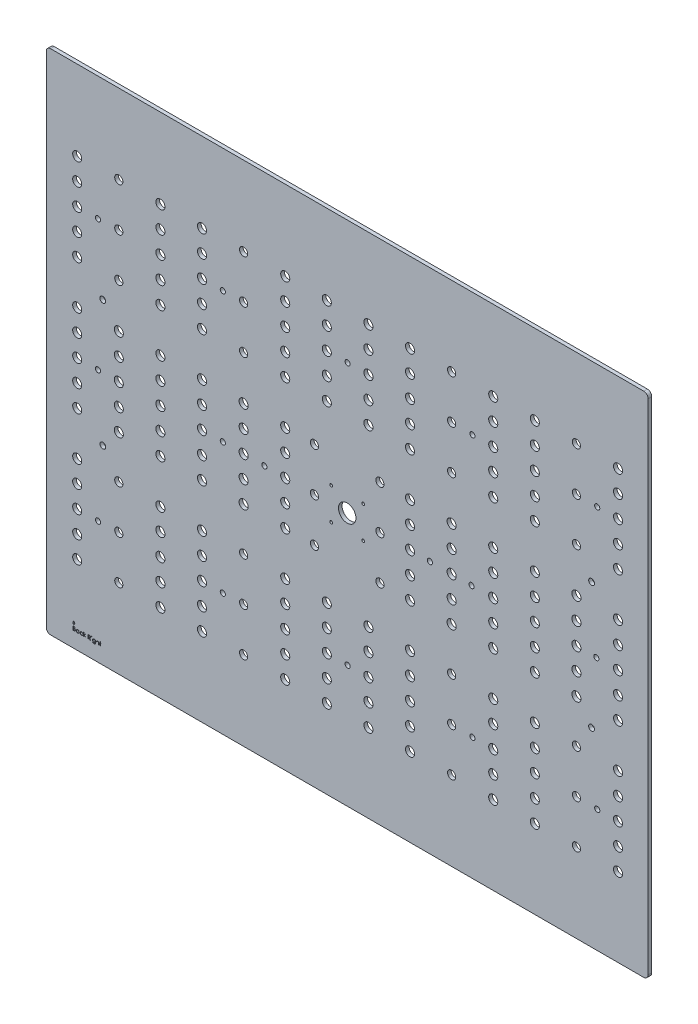
from build123d import *

# Parameters (mm, degrees)
SKETCH1_W                         = 578.0532
SKETCH1_H                         = 495.85372
BOSS_EXTRUDE1_DEPTH               = 3.175
SKETCH8_W                         = 19.431
SKETCH8_H                         = 19.431
CORNERS_DEPTH                     = 4.175
SKETCH13_R                        = 7.62
CAMERA_HOLE_DEPTH                 = 4.175
SKETCH12_R                        = 3.96875
LED_HOLES_DEPTH                   = 4.175
CUT_EXTRUDE7_DEPTH                = 4.175
FILLET1_R                         = 2.54
LPATTERN1_COUNT                   = 14
LPATTERN1_PITCH                   = 36.322
LPATTERN1_COUNT_DIR2              = 3
LPATTERN1_PITCH_DIR2              = 114.3
SKETCH17_R                        = 3.571875
WHITE_LED_DEPTH                   = 4.175
LPATTERN3_COUNT                   = 3
LPATTERN3_PITCH                   = 228.6
LPATTERN3_COUNT_DIR2              = 12
LPATTERN3_PITCH_DIR2              = 36.322
SKETCH18_R                        = 3.571875
WHITE_LED2_DEPTH                  = 4.175
F_8_CLEARANCE_HOLE_LIGHT_STRAP_D  = 4.4958
F_2_CLEARANCE_HOLE_CAMERA_MOUNT_D = 2.4384
LPATTERN7_COUNT                   = 5
LPATTERN7_PITCH                   = 108.966
F_8_CLEARANCE_HOLE_STRAP_HOLES_D  = 4.4958
SKETCH26_W                        = 651.271962381
SKETCH26_H                        = 575.691192957
SKETCH26_W_2                      = 525.4625
SKETCH26_H_2                      = 443.27572
OUTER_CIMENSIONS_TEMP_DEPTH       = 4.175
FILLET2_R                         = 3.81
F_10_CLEARANCE_HOLE1_D            = 5.1054
SKETCH29_W                        = 0.314102564
SKETCH29_H                        = 2.557692307
CUT_EXTRUDE8_DEPTH                = 1.27


with BuildPart() as part:
    # Sketch1 → Boss-Extrude1 (new body)
    with BuildSketch(Plane.XY):
        with Locations((169.253006723, -23.184095462)):
            Rectangle(SKETCH1_W, SKETCH1_H)
    extrude(amount=BOSS_EXTRUDE1_DEPTH)

    # Sketch8 → Corners (cut, through all)
    with BuildSketch(Plane.XY.offset(3.175)):
        with Locations((-110.058093277, 215.027264538)):
            Rectangle(SKETCH8_W, SKETCH8_H)
        with Locations((448.564106723, 215.027264538)):
            Rectangle(SKETCH8_W, SKETCH8_H)
        with Locations((448.564106723, -261.395455462)):
            Rectangle(SKETCH8_W, SKETCH8_H)
        with Locations((-110.058093277, -261.395455462)):
            Rectangle(SKETCH8_W, SKETCH8_H)
    extrude(amount=-CORNERS_DEPTH, mode=Mode.SUBTRACT)

    # Sketch13 → camera hole (cut, through all)
    with BuildSketch(Plane.XY.offset(3.175)):
        with Locations((169.253006723, -23.184095462)):
            Circle(SKETCH13_R)
    extrude(amount=-CAMERA_HOLE_DEPTH, mode=Mode.SUBTRACT)

    # Sketch12 → LED holes (cut, through all)
    with BuildSketch(Plane(origin=(0, 0, 0), x_dir=(-1, 0, 0), z_dir=(0, 0, -1))):
        with Locations((66.458993277, 52.507904538)):
            Circle(SKETCH12_R)
        with Locations((66.458993277, 71.557904538)):
            Circle(SKETCH12_R)
        with Locations((66.458993277, 90.607904538)):
            Circle(SKETCH12_R)
        with Locations((66.458993277, 109.657904538)):
            Circle(SKETCH12_R)
        with Locations((66.458993277, 128.707904538)):
            Circle(SKETCH12_R)
    led_holes = extrude(amount=-LED_HOLES_DEPTH, mode=Mode.SUBTRACT)

    # Sketch15 → Cut-Extrude7 (cut, through all)
    with BuildSketch(Plane.XY.offset(3.175)):
        Polygon((-100.342593277, 224.742764538), (438.848606723, 224.742764538), (438.848606723, 205.311764538), (458.279606723, 205.311764538), (458.279606723, -251.679955462), (438.848606723, -251.679955462), (438.848606723, -271.110955462), (-100.342593277, -271.110955462), (-100.342593277, -251.679955462), (-119.773593277, -251.679955462), (-119.773593277, 205.311764538), (-100.342593277, 205.311764538), align=None)
        Polygon((-99.834593277, 224.234764538), (438.340606723, 224.234764538), (438.340606723, 204.803764538), (457.771606723, 204.803764538), (457.771606723, -251.171955462), (438.340606723, -251.171955462), (438.340606723, -270.602955462), (-99.834593277, -270.602955462), (-99.834593277, -251.171955462), (-119.265593277, -251.171955462), (-119.265593277, 204.803764538), (-99.834593277, 204.803764538), align=None, mode=Mode.SUBTRACT)
    extrude(amount=-CUT_EXTRUDE7_DEPTH, mode=Mode.SUBTRACT)

    # Fillet1
    fillet1_edges = [part.edges().sort_by_distance(p)[0] for p in [
        (-99.834593277, 224.234764538, 1.5875),
        (438.340606723, 224.234764538, 1.5875),
        (457.771606723, 204.803764538, 1.5875),
        (457.771606723, -251.171955462, 1.5875),
        (438.340606723, -270.602955462, 1.5875),
        (-99.834593277, -270.602955462, 1.5875),
        (-119.265593277, -251.171955462, 1.5875),
        (-119.265593277, 204.803764538, 1.5875),
    ]]
    fillet(fillet1_edges, radius=FILLET1_R)

    # LPattern1: LED holes 14 × 3, 10 skipped
    with Locations(*[(i * LPATTERN1_PITCH, -j * LPATTERN1_PITCH_DIR2, 0) for i in range(LPATTERN1_COUNT) for j in range(LPATTERN1_COUNT_DIR2) if (i, j) not in ((0, 0), (1, 0), (1, 2), (4, 0), (4, 2), (6, 1), (7, 1), (9, 0), (9, 2), (12, 0), (12, 2))]):
        add(led_holes, mode=Mode.SUBTRACT)

    # Sketch17 → White LED (cut, through all)
    with BuildSketch(Plane(origin=(0, 0, 0), x_dir=(-1, 0, 0), z_dir=(0, 0, -1))):
        with Locations((30.136993277, 53.015904538)):
            Circle(SKETCH17_R)
        with Locations((30.136993277, 91.115904538)):
            Circle(SKETCH17_R)
        with Locations((30.136993277, 129.215904538)):
            Circle(SKETCH17_R)
    white_led = extrude(amount=-WHITE_LED_DEPTH, mode=Mode.SUBTRACT)

    # LPattern3: White LED 3 × 12, 16 skipped
    with Locations(*[(j * LPATTERN3_PITCH_DIR2, -i * LPATTERN3_PITCH, 0) for i in range(LPATTERN3_COUNT) for j in range(LPATTERN3_COUNT_DIR2) if (i, j) not in ((0, 0), (0, 1), (0, 2), (0, 4), (0, 5), (0, 6), (0, 7), (0, 9), (0, 10), (1, 1), (1, 2), (1, 4), (1, 5), (1, 6), (1, 7), (1, 9), (1, 10))]):
        add(white_led, mode=Mode.SUBTRACT)

    # Sketch18 → White LED2 (cut, through all)
    with BuildSketch(Plane(origin=(0, 0, 0), x_dir=(-1, 0, 0), z_dir=(0, 0, -1))):
        with Locations((-140.678006723, -61.792095462)):
            Circle(SKETCH18_R)
        with Locations((-197.828006723, -61.792095462)):
            Circle(SKETCH18_R)
        with Locations((-197.828006723, -23.692095462)):
            Circle(SKETCH18_R)
        with Locations((-197.828006723, 14.407904538)):
            Circle(SKETCH18_R)
        with Locations((-140.678006723, -23.692095462)):
            Circle(SKETCH18_R)
        with Locations((-140.678006723, 14.407904538)):
            Circle(SKETCH18_R)
    extrude(amount=-WHITE_LED2_DEPTH, mode=Mode.SUBTRACT)

    # #8 Clearance Hole light strap (through all)
    with Locations(Plane(origin=(0, 0, 0), x_dir=(-1, 0, 0), z_dir=(0, 0, -1))):
        with Locations((48.297993277, 90.607904538), (48.297993277, -137.992095462)):
            f_8_clearance_hole_light_strap = Hole(F_8_CLEARANCE_HOLE_LIGHT_STRAP_D / 2)

    # #2 Clearance Hole Camera Mount (through all)
    with Locations(Plane.XY.offset(3.175)):
        with Locations((155.283006723, -9.214095462), (183.223006723, -9.214095462), (183.223006723, -37.154095462), (155.283006723, -37.154095462)):
            Hole(F_2_CLEARANCE_HOLE_CAMERA_MOUNT_D / 2)

    # LPattern7: #8 Clearance Hole light strap ×5
    with Locations(*[(i * LPATTERN7_PITCH, 0, 0) for i in range(1, LPATTERN7_COUNT)]):
        add(f_8_clearance_hole_light_strap, mode=Mode.SUBTRACT)

    # #8 Clearance Hole Strap holes (through all)
    with Locations(Plane.XY.offset(3.175)):
        with Locations((-48.297993277, -23.692095462), (60.668006723, -23.692095462), (96.990006723, -23.692095462), (241.516006723, -23.692095462), (277.838006723, -23.692095462), (386.804006723, -23.692095462)):
            Hole(F_8_CLEARANCE_HOLE_STRAP_HOLES_D / 2)

    # Sketch26 → Outer Cimensions (temp) (cut, through all)
    with BuildSketch(Plane.XY.offset(3.175)):
        with Locations((175.732860109, -14.260001289)):
            Rectangle(SKETCH26_W, SKETCH26_H)
        with Locations((169.253006723, -23.184095462)):
            Rectangle(SKETCH26_W_2, SKETCH26_H_2, mode=Mode.SUBTRACT)
    extrude(amount=-OUTER_CIMENSIONS_TEMP_DEPTH, mode=Mode.SUBTRACT)

    # Fillet2
    fillet2_edges = [part.edges().sort_by_distance(p)[0] for p in [
        (-93.478243277, 198.453764538, 1.5875),
        (431.984256723, 198.453764538, 1.5875),
        (431.984256723, -244.821955462, 1.5875),
        (-93.478243277, -244.821955462, 1.5875),
    ]]
    fillet(fillet2_edges, radius=FILLET2_R)

    # #10 Clearance Hole1 (through all)
    with Locations(Plane.XY.offset(3.175)):
        with Locations((-44.106993277, -78.793166362), (382.613006723, -78.793166362), (382.613006723, 31.408975438), (-44.106993277, 31.408975438)):
            Hole(F_10_CLEARANCE_HOLE1_D / 2)

    # Sketch29 → Cut-Extrude8 (cut)
    with BuildSketch(Plane.XY.offset(3.175)):
        Polygon((-69.411743277, -224.208312288), (-70.427743277, -225.478312288), (-69.919743277, -225.478312288), (-69.919743277, -226.748312288), (-68.903743277, -226.748312288), (-68.903743277, -225.478312288), (-68.395743277, -225.478312288), align=None)
        with BuildLine():
            Line((-69.979025329, -228.033666458), (-69.2961327, -228.033666458))
            add(Edge.make_bspline(
                [(-69.2961327, -228.033666458), (-69.262704222, -228.033842209), (-69.197911512, -228.034182857), (-69.10369207, -228.039465988), (-69.015443259, -228.046669658), (-68.933139487, -228.058099751), (-68.856818785, -228.071891528), (-68.786251147, -228.088593344), (-68.721660975, -228.108619957), (-68.644548239, -228.140466239), (-68.556627578, -228.187789407), (-68.461429185, -228.257717972), (-68.380024946, -228.343250435), (-68.309838629, -228.439733091), (-68.254037509, -228.545868862), (-68.213668212, -228.659128051), (-68.188110336, -228.778049793), (-68.185481902, -228.859692971), (-68.184153534, -228.900954119)],
                knots=[0, 0, 0, 0, 0.00010027, 0.000194349, 0.000283026, 0.000365821, 0.000443519, 0.000515622, 0.000583254, 0.00064614, 0.000765662, 0.000881909, 0.000998927, 0.001118415, 0.001238844, 0.00135727, 0.001478274, 0.001601912, 0.001601912, 0.001601912, 0.001601912], degree=3))
            add(Edge.make_bspline(
                [(-68.184153534, -228.900954119), (-68.185246752, -228.939606674), (-68.187395029, -229.015562591), (-68.207937789, -229.126656701), (-68.240098457, -229.23240792), (-68.284803706, -229.332430305), (-68.342905703, -229.424463918), (-68.411764021, -229.509251184), (-68.494840824, -229.583202241), (-68.557084064, -229.624545144), (-68.588700809, -229.645545465)],
                knots=[0, 0, 0, 0, 0.000115857, 0.00022767, 0.000337672, 0.000446877, 0.000555233, 0.000663318, 0.000773539, 0.000887324, 0.000887324, 0.000887324, 0.000887324], degree=3))
            add(Edge.make_bspline(
                [(-68.588700809, -229.645545465), (-68.548940382, -229.660810464), (-68.472868834, -229.690016188), (-68.368182822, -229.741651652), (-68.277987977, -229.797813763), (-68.201590831, -229.859145613), (-68.136253176, -229.925254424), (-68.079200234, -229.997109538), (-68.03051886, -230.075648296), (-67.988805937, -230.160051831), (-67.956257181, -230.249458299), (-67.931881276, -230.343029075), (-67.917913827, -230.440428631), (-67.915926186, -230.50671401), (-67.914922764, -230.540176875)],
                knots=[0, 0, 0, 0, 0.000127722, 0.000244363, 0.000349599, 0.000445847, 0.000537565, 0.000627901, 0.000720503, 0.000814257, 0.000909859, 0.001005428, 0.001103887, 0.001204268, 0.001204268, 0.001204268, 0.001204268], degree=3))
            add(Edge.make_bspline(
                [(-67.914922764, -230.540176875), (-67.915899611, -230.574343747), (-67.917821582, -230.641568025), (-67.932001554, -230.74032316), (-67.956010661, -230.834698107), (-67.989081808, -230.925303289), (-68.032244122, -231.011963424), (-68.084772087, -231.094776688), (-68.14740365, -231.172911018), (-68.217466519, -231.247234641), (-68.296728665, -231.314062429), (-68.382244419, -231.373578135), (-68.475090739, -231.422524198), (-68.573742733, -231.463640219), (-68.67930705, -231.495047418), (-68.791309657, -231.517019991), (-68.909653959, -231.531825028), (-68.99086371, -231.533042233), (-69.032510906, -231.533666458)],
                knots=[0, 0, 0, 0, 0.000102481, 0.000201635, 0.000298562, 0.000394165, 0.000490425, 0.000588455, 0.000687769, 0.000790423, 0.000894381, 0.000998232, 0.001102369, 0.001208616, 0.001318415, 0.001432129, 0.001550749, 0.00167562, 0.00167562, 0.00167562, 0.00167562], degree=3))
            Line((-69.032510906, -231.533666458), (-69.979025329, -231.533666458))
            Line((-69.979025329, -231.533666458), (-69.979025329, -228.033666458))
        make_face()
        with BuildLine():
            Line((-69.664922764, -228.392640817), (-69.664922764, -229.514435689))
            Line((-69.664922764, -229.514435689), (-69.453885104, -229.514435689))
            add(Edge.make_bspline(
                [(-69.453885104, -229.514435689), (-69.423036309, -229.514035766), (-69.36343015, -229.513263033), (-69.277110253, -229.511049516), (-69.196985235, -229.504851473), (-69.123193402, -229.498655211), (-69.055850958, -229.488580623), (-68.995107096, -229.4765885), (-68.940008499, -229.463905595), (-68.876468954, -229.442336108), (-68.804396005, -229.410458433), (-68.727562901, -229.360986597), (-68.659828432, -229.302062244), (-68.602631244, -229.234071282), (-68.555819773, -229.159205096), (-68.523306058, -229.078658216), (-68.501258774, -228.994438084), (-68.499267243, -228.936619831), (-68.498256098, -228.907264215)],
                knots=[0, 0, 0, 0, 9.2559e-05, 0.000178842, 0.000258967, 0.000333616, 0.000400942, 0.000463093, 0.000519379, 0.000570374, 0.000664201, 0.000755025, 0.000843472, 0.000932526, 0.001020669, 0.001107124, 0.001192318, 0.001280185, 0.001280185, 0.001280185, 0.001280185], degree=3))
            add(Edge.make_bspline(
                [(-68.498256098, -228.907264215), (-68.498782278, -228.887838443), (-68.499814438, -228.849732671), (-68.508267741, -228.794183317), (-68.522635315, -228.741939565), (-68.541089608, -228.692285454), (-68.566878297, -228.646773604), (-68.59724176, -228.603830408), (-68.63392745, -228.56491829), (-68.675684763, -228.528548792), (-68.723693386, -228.496304264), (-68.777924678, -228.468063501), (-68.839112355, -228.445322724), (-68.90622521, -228.425406571), (-68.980296297, -228.411418278), (-69.060470851, -228.39976489), (-69.14740557, -228.393832148), (-69.207550672, -228.393046785), (-69.238640713, -228.392640817)],
                knots=[0, 0, 0, 0, 5.8261e-05, 0.000114285, 0.000168029, 0.000220632, 0.000272728, 0.000324483, 0.000378062, 0.000432741, 0.000490301, 0.000551137, 0.000615721, 0.000685833, 0.000760908, 0.00084162, 0.000928788, 0.00102206, 0.00102206, 0.00102206, 0.00102206], degree=3))
            Line((-69.238640713, -228.392640817), (-69.664922764, -228.392640817))
        make_face(mode=Mode.SUBTRACT)
        with BuildLine():
            Line((-69.664922764, -229.873410048), (-69.664922764, -231.174692099))
            Line((-69.664922764, -231.174692099), (-69.217607059, -231.174692099))
            add(Edge.make_bspline(
                [(-69.217607059, -231.174692099), (-69.185588133, -231.174308352), (-69.123875875, -231.17356873), (-69.034774645, -231.171154175), (-68.952191541, -231.165661899), (-68.876503405, -231.15701605), (-68.806892953, -231.1476376), (-68.74419525, -231.13502632), (-68.687902056, -231.120577359), (-68.622627748, -231.098243187), (-68.54912424, -231.063546716), (-68.469913384, -231.011232489), (-68.399487166, -230.948909182), (-68.339681906, -230.876778268), (-68.290668918, -230.798346941), (-68.255013463, -230.715201591), (-68.233022606, -230.628716063), (-68.230360437, -230.569749351), (-68.229025329, -230.540176875)],
                knots=[0, 0, 0, 0, 9.6064e-05, 0.000185151, 0.000267373, 0.000344257, 0.000413665, 0.000478015, 0.000536005, 0.000587888, 0.000684801, 0.000778918, 0.000871787, 0.000965866, 0.001059062, 0.00114827, 0.001236355, 0.001324974, 0.001324974, 0.001324974, 0.001324974], degree=3))
            add(Edge.make_bspline(
                [(-68.229025329, -230.540176875), (-68.229301433, -230.521683535), (-68.229849188, -230.484995153), (-68.238109803, -230.431079334), (-68.250123673, -230.37885346), (-68.265655107, -230.32817572), (-68.288274574, -230.279962344), (-68.314681119, -230.233259784), (-68.34564252, -230.188006305), (-68.393886686, -230.130794051), (-68.464058671, -230.064877038), (-68.563765446, -230.000339536), (-68.677137744, -229.948291729), (-68.759365237, -229.926192252), (-68.801841835, -229.914776234)],
                knots=[0, 0, 0, 0, 5.5429e-05, 0.000109963, 0.000163198, 0.000216191, 0.000268588, 0.000322593, 0.000377046, 0.000432793, 0.000546889, 0.000664343, 0.000787646, 0.000919405, 0.000919405, 0.000919405, 0.000919405], degree=3))
            add(Edge.make_bspline(
                [(-68.801841835, -229.914776234), (-68.818870931, -229.91132115), (-68.855793523, -229.903829815), (-68.916001104, -229.895922112), (-68.984736973, -229.888877052), (-69.06215985, -229.883665895), (-69.148367691, -229.878279351), (-69.24354461, -229.87618453), (-69.347301924, -229.87368527), (-69.419294297, -229.873504136), (-69.456689591, -229.873410048)],
                knots=[0, 0, 0, 0, 5.2115e-05, 0.000112995, 0.000182062, 0.000259389, 0.000345767, 0.00044116, 0.000544948, 0.000657129, 0.000657129, 0.000657129, 0.000657129], degree=3))
            Line((-69.456689591, -229.873410048), (-69.664922764, -229.873410048))
        make_face(mode=Mode.SUBTRACT)
        with BuildLine():
            Line((-64.684153534, -228.975974151), (-64.684153534, -231.533666458))
            Line((-64.684153534, -231.533666458), (-64.998256098, -231.533666458))
            Line((-64.998256098, -231.533666458), (-64.998256098, -231.091258606))
            add(Edge.make_bspline(
                [(-64.998256098, -231.091258606), (-65.033674888, -231.1312982), (-65.102795104, -231.209435971), (-65.218236222, -231.311518143), (-65.3406044, -231.395896465), (-65.469305721, -231.464046381), (-65.604223964, -231.515238437), (-65.745060051, -231.551624596), (-65.891871432, -231.575018431), (-65.992123787, -231.577354453), (-66.042927572, -231.578538253)],
                knots=[0, 0, 0, 0, 0.000160263, 0.000312755, 0.000460949, 0.000605216, 0.000748578, 0.000892786, 0.001041028, 0.001193333, 0.001193333, 0.001193333, 0.001193333], degree=3))
            add(Edge.make_bspline(
                [(-66.042927572, -231.578538253), (-66.088095526, -231.577311881), (-66.177168731, -231.574893421), (-66.308197808, -231.556131117), (-66.434290057, -231.526000495), (-66.55556463, -231.484099606), (-66.671236776, -231.428518784), (-66.782296872, -231.361977536), (-66.888169564, -231.282736706), (-66.987241103, -231.192148678), (-67.078473104, -231.093753691), (-67.158534376, -230.988808144), (-67.225287456, -230.87776584), (-67.281107537, -230.762032686), (-67.324103881, -230.640717766), (-67.354077516, -230.514240598), (-67.372817962, -230.382750725), (-67.375235423, -230.293211202), (-67.376461226, -230.247809087)],
                knots=[0, 0, 0, 0, 0.000135464, 0.00026714, 0.000396211, 0.000523931, 0.000651257, 0.000780517, 0.000911767, 0.001047265, 0.00118272, 0.001313831, 0.001442491, 0.001570752, 0.001698704, 0.001827775, 0.001960146, 0.00209631, 0.00209631, 0.00209631, 0.00209631], degree=3))
            add(Edge.make_bspline(
                [(-67.376461226, -230.247809087), (-67.375208255, -230.203345383), (-67.372731198, -230.11544304), (-67.354277978, -229.986164342), (-67.323246969, -229.861646081), (-67.279699122, -229.742289138), (-67.223857167, -229.627949088), (-67.15592908, -229.518545063), (-67.075909955, -229.413775665), (-66.983657548, -229.316104438), (-66.883722778, -229.225883824), (-66.776814047, -229.147474779), (-66.665590766, -229.07975793), (-66.548327755, -229.026104454), (-66.42676065, -228.982695349), (-66.299807204, -228.952662381), (-66.167995626, -228.93496506), (-66.078505134, -228.932402296), (-66.033111867, -228.931102356)],
                knots=[0, 0, 0, 0, 0.000133363, 0.00026365, 0.000390846, 0.000517716, 0.000644083, 0.000771912, 0.000903449, 0.001038867, 0.001174416, 0.001306792, 0.001436052, 0.00156435, 0.001692963, 0.001822716, 0.001954992, 0.002091156, 0.002091156, 0.002091156, 0.002091156], degree=3))
            add(Edge.make_bspline(
                [(-66.033111867, -228.931102356), (-65.980912008, -228.932540107), (-65.878550548, -228.93535947), (-65.728822539, -228.958822198), (-65.587178061, -228.998460665), (-65.452523709, -229.052378163), (-65.325343023, -229.124026892), (-65.206840038, -229.214406853), (-65.095774555, -229.32294804), (-65.031394263, -229.406318484), (-64.998256098, -229.449231362)],
                knots=[0, 0, 0, 0, 0.00015654, 0.000306968, 0.000453261, 0.000596998, 0.000741098, 0.000889738, 0.001042937, 0.001205434, 0.001205434, 0.001205434, 0.001205434], degree=3))
            Line((-64.998256098, -229.449231362), (-64.998256098, -228.975974151))
            Line((-64.998256098, -228.975974151), (-64.684153534, -228.975974151))
        make_face()
        with BuildLine():
            add(Edge.make_bspline(
                [(-66.028905136, -229.24520492), (-66.074819474, -229.246838558), (-66.165447074, -229.250063099), (-66.298491076, -229.275236594), (-66.42580449, -229.317121188), (-66.546750565, -229.374403089), (-66.659418781, -229.446431826), (-66.760112452, -229.533553209), (-66.849655153, -229.633390224), (-66.924963418, -229.745492334), (-66.986353915, -229.865670425), (-67.029520946, -229.991294863), (-67.057990194, -230.120099841), (-67.060898714, -230.207462526), (-67.062358662, -230.251314696)],
                knots=[0, 0, 0, 0, 0.000137677, 0.000271753, 0.000404561, 0.000538791, 0.000672205, 0.000804452, 0.00093703, 0.001073348, 0.00120849, 0.001340643, 0.001470999, 0.001602378, 0.001602378, 0.001602378, 0.001602378], degree=3))
            add(Edge.make_bspline(
                [(-67.062358662, -230.251314696), (-67.060493769, -230.294904803), (-67.056771292, -230.381914159), (-67.030020597, -230.510894735), (-66.985140724, -230.636548778), (-66.923898661, -230.757809771), (-66.847212036, -230.870393871), (-66.758323384, -230.972133994), (-66.656373103, -231.059623582), (-66.543445596, -231.132861156), (-66.422837625, -231.192023677), (-66.296003694, -231.233189316), (-66.165328055, -231.259767097), (-66.076475722, -231.262871574), (-66.031709623, -231.264435689)],
                knots=[0, 0, 0, 0, 0.000130727, 0.000260941, 0.000393327, 0.000530037, 0.000667328, 0.000800955, 0.000934191, 0.001068956, 0.001203792, 0.001335934, 0.001468075, 0.001602253, 0.001602253, 0.001602253, 0.001602253], degree=3))
            add(Edge.make_bspline(
                [(-66.031709623, -231.264435689), (-65.986263121, -231.262775725), (-65.895874534, -231.259474222), (-65.762435826, -231.234192956), (-65.632940864, -231.192424158), (-65.509153635, -231.134525031), (-65.393837504, -231.062767675), (-65.290339626, -230.978760584), (-65.202823658, -230.8810574), (-65.128631048, -230.773680947), (-65.070455632, -230.655968951), (-65.028079573, -230.53063476), (-65.003025667, -230.397674012), (-64.999867937, -230.306810085), (-64.998256098, -230.260429279)],
                knots=[0, 0, 0, 0, 0.000136278, 0.000271043, 0.000405851, 0.000543552, 0.000679927, 0.000812429, 0.000941985, 0.001072088, 0.00120284, 0.001334538, 0.001467925, 0.001607002, 0.001607002, 0.001607002, 0.001607002], degree=3))
            add(Edge.make_bspline(
                [(-64.998256098, -230.260429279), (-64.999215754, -230.225091448), (-65.001104662, -230.155535415), (-65.015535231, -230.053407898), (-65.038490158, -229.955674172), (-65.070836328, -229.862231482), (-65.113327612, -229.773596467), (-65.164575378, -229.689132707), (-65.225480828, -229.609279495), (-65.295063524, -229.535136424), (-65.371228726, -229.467509962), (-65.451823267, -229.407145722), (-65.537802014, -229.357556949), (-65.627719051, -229.316515677), (-65.721730385, -229.283856527), (-65.820601005, -229.262068834), (-65.923279992, -229.247108513), (-65.993326047, -229.245846132), (-66.028905136, -229.24520492)],
                knots=[0, 0, 0, 0, 0.000105983, 0.000208608, 0.000308773, 0.00040678, 0.000504626, 0.000603105, 0.000702667, 0.00080535, 0.000907651, 0.001007914, 0.001106881, 0.00120477, 0.001304102, 0.001404791, 0.00150811, 0.001614764, 0.001614764, 0.001614764, 0.001614764], degree=3))
        make_face(mode=Mode.SUBTRACT)
        with BuildLine():
            Line((-61.453384303, -229.530561491), (-61.716304976, -229.693922869))
            add(Edge.make_bspline(
                [(-61.716304976, -229.693922869), (-61.745134841, -229.658094475), (-61.801881537, -229.587572365), (-61.900420773, -229.496562431), (-62.005432187, -229.41839539), (-62.118710235, -229.354691639), (-62.240096035, -229.305470188), (-62.369110886, -229.270639983), (-62.505736391, -229.24893574), (-62.59940159, -229.246468903), (-62.64739472, -229.24520492)],
                knots=[0, 0, 0, 0, 0.0001378, 0.000271237, 0.000401088, 0.000529797, 0.000659994, 0.000793002, 0.000929944, 0.001073845, 0.001073845, 0.001073845, 0.001073845], degree=3))
            add(Edge.make_bspline(
                [(-62.64739472, -229.24520492), (-62.685753677, -229.246261762), (-62.761300599, -229.248343184), (-62.872206753, -229.261353678), (-62.977849106, -229.284995686), (-63.078889815, -229.316146643), (-63.174610233, -229.357896933), (-63.265261152, -229.408706689), (-63.351646642, -229.467756729), (-63.431263383, -229.536167274), (-63.50409239, -229.610565942), (-63.567191304, -229.690319637), (-63.622128237, -229.773039529), (-63.665234194, -229.860791271), (-63.700509364, -229.951567324), (-63.723716084, -230.04708118), (-63.73918078, -230.146109187), (-63.740950108, -230.213627527), (-63.741845841, -230.247809087)],
                knots=[0, 0, 0, 0, 0.000115089, 0.000226664, 0.000334347, 0.000439455, 0.000543394, 0.000646972, 0.000750824, 0.000856758, 0.000961376, 0.00106266, 0.001161449, 0.00125865, 0.001355399, 0.001453007, 0.001552955, 0.001655437, 0.001655437, 0.001655437, 0.001655437], degree=3))
            add(Edge.make_bspline(
                [(-63.741845841, -230.247809087), (-63.740066589, -230.292578298), (-63.736532059, -230.381513493), (-63.708830599, -230.512791595), (-63.663486192, -230.639715286), (-63.601428341, -230.761383423), (-63.522951207, -230.873977578), (-63.430778643, -230.974961032), (-63.32485956, -231.062377061), (-63.206127229, -231.134849586), (-63.077369486, -231.193110953), (-62.939979381, -231.234618286), (-62.795079601, -231.259670659), (-62.695872854, -231.262826602), (-62.645291354, -231.264435689)],
                knots=[0, 0, 0, 0, 0.000134224, 0.00026664, 0.000400581, 0.000537609, 0.000675117, 0.000811087, 0.000946551, 0.001085679, 0.001227203, 0.001369372, 0.001515181, 0.001666857, 0.001666857, 0.001666857, 0.001666857], degree=3))
            add(Edge.make_bspline(
                [(-62.645291354, -231.264435689), (-62.59893617, -231.263136192), (-62.507835931, -231.260582335), (-62.374668646, -231.239053372), (-62.247888736, -231.203809738), (-62.127500705, -231.154662088), (-62.013724539, -231.091134572), (-61.907295364, -231.012775402), (-61.806095426, -230.921838801), (-61.746598449, -230.85152083), (-61.716304976, -230.815717741)],
                knots=[0, 0, 0, 0, 0.000138999, 0.00027317, 0.000403475, 0.000533023, 0.000662344, 0.000793326, 0.000928824, 0.001069379, 0.001069379, 0.001069379, 0.001069379], degree=3))
            Line((-61.716304976, -230.815717741), (-61.453384303, -230.988193702))
            add(Edge.make_bspline(
                [(-61.453384303, -230.988193702), (-61.468972005, -231.011084429), (-61.500095672, -231.056789906), (-61.552123298, -231.121234022), (-61.608243129, -231.181555705), (-61.668236226, -231.237674095), (-61.731319236, -231.290932114), (-61.799647146, -231.338783688), (-61.871016757, -231.383918511), (-61.946265915, -231.424531383), (-62.024616613, -231.461037705), (-62.105958602, -231.492428876), (-62.189938415, -231.519398982), (-62.276654791, -231.540836328), (-62.36627869, -231.557947167), (-62.458578324, -231.569300868), (-62.553521906, -231.577776149), (-62.617694057, -231.578282016), (-62.650199207, -231.578538253)],
                knots=[0, 0, 0, 0, 8.3056e-05, 0.000165835, 0.000248187, 0.000330026, 0.000412165, 0.000495625, 0.000580051, 0.000665384, 0.00075196, 0.000839196, 0.00092678, 0.001016395, 0.001107013, 0.001200326, 0.001295291, 0.001392769, 0.001392769, 0.001392769, 0.001392769], degree=3))
            add(Edge.make_bspline(
                [(-62.650199207, -231.578538253), (-62.69981009, -231.577646974), (-62.797047783, -231.575900059), (-62.93937029, -231.556691583), (-63.075383957, -231.527733967), (-63.205042315, -231.486170233), (-63.32836555, -231.432665458), (-63.445238668, -231.367308543), (-63.555274686, -231.289556753), (-63.657385469, -231.200793984), (-63.751166915, -231.104553343), (-63.831693105, -231.000703425), (-63.901538376, -230.893062377), (-63.957625919, -230.779252851), (-64.002272845, -230.660787479), (-64.032777678, -230.536717239), (-64.052507416, -230.408064985), (-64.054790795, -230.320332103), (-64.055948406, -230.275853958)],
                knots=[0, 0, 0, 0, 0.000148744, 0.000291539, 0.000430022, 0.000565498, 0.000699266, 0.000832672, 0.000966504, 0.001102706, 0.001238073, 0.00136893, 0.00149632, 0.001622368, 0.001748823, 0.001875338, 0.002005032, 0.002138395, 0.002138395, 0.002138395, 0.002138395], degree=3))
            add(Edge.make_bspline(
                [(-64.055948406, -230.275853958), (-64.055507389, -230.245675524), (-64.054630135, -230.185645637), (-64.044568208, -230.09655057), (-64.031569735, -230.008642025), (-64.009543998, -229.923034305), (-63.984103366, -229.838429015), (-63.951627834, -229.755845914), (-63.913532439, -229.674901241), (-63.870280492, -229.595803511), (-63.821591747, -229.519853972), (-63.767710514, -229.448100307), (-63.710666177, -229.379680542), (-63.647790065, -229.316956781), (-63.581750412, -229.25742059), (-63.510678836, -229.202662465), (-63.434982984, -229.152521475), (-63.355799662, -229.106070459), (-63.27317495, -229.064711024), (-63.18760828, -229.029077786), (-63.099615251, -228.99862521), (-63.009055107, -228.974516291), (-62.916528933, -228.954298868), (-62.821307595, -228.941581021), (-62.723755373, -228.932594748), (-62.657699351, -228.931603956), (-62.6242577, -228.931102356)],
                knots=[0, 0, 0, 0, 9.0488e-05, 0.000179996, 0.000268751, 0.000356836, 0.000444879, 0.000533675, 0.000622751, 0.00071312, 0.000803944, 0.000893127, 0.000982181, 0.001070925, 0.00115931, 0.001248782, 0.001339788, 0.001431538, 0.001524036, 0.001616746, 0.001709427, 0.001803141, 0.001897749, 0.001993333, 0.002091151, 0.002191451, 0.002191451, 0.002191451, 0.002191451], degree=3))
            add(Edge.make_bspline(
                [(-62.6242577, -228.931102356), (-62.582377592, -228.932024247), (-62.498826713, -228.933863421), (-62.374886006, -228.949342073), (-62.252770812, -228.97267849), (-62.134623709, -229.007251319), (-62.021877194, -229.049114975), (-61.916341744, -229.09612769), (-61.82050164, -229.150722293), (-61.732574051, -229.210442407), (-61.652394534, -229.277803313), (-61.579140041, -229.35361027), (-61.511308392, -229.43746875), (-61.47285168, -229.499274481), (-61.453384303, -229.530561491)],
                knots=[0, 0, 0, 0, 0.000125597, 0.000250566, 0.00037418, 0.000498223, 0.000619345, 0.000734815, 0.00084439, 0.000949794, 0.001053299, 0.001157917, 0.001265662, 0.001376119, 0.001376119, 0.001376119, 0.001376119], degree=3))
        make_face()
        Polygon((-60.825179175, -227.943922869), (-60.511076611, -227.943922869), (-60.511076611, -230.019243382), (-59.347214431, -228.975974151), (-58.895691995, -228.975974151), (-60.246052572, -230.187512612), (-58.761076611, -231.533666458), (-59.211897925, -231.533666458), (-60.511076611, -230.355080721), (-60.511076611, -231.533666458), (-60.825179175, -231.533666458), align=None)
        with BuildLine():
            Line((-56.966204816, -228.033666458), (-56.265784143, -228.033666458))
            add(Edge.make_bspline(
                [(-56.265784143, -228.033666458), (-56.219043014, -228.033822044), (-56.12929487, -228.034120787), (-56.000721599, -228.03578655), (-55.883894502, -228.040560905), (-55.778874663, -228.044669489), (-55.685664008, -228.05216143), (-55.603976717, -228.059322077), (-55.53418902, -228.068695738), (-55.491943169, -228.077401161), (-55.472815393, -228.081342741)],
                knots=[0, 0, 0, 0, 0.000140226, 0.00026925, 0.000385712, 0.000490995, 0.000584507, 0.000666202, 0.000736998, 0.000795574, 0.000795574, 0.000795574, 0.000795574], degree=3))
            add(Edge.make_bspline(
                [(-55.472815393, -228.081342741), (-55.447208769, -228.087669506), (-55.396541779, -228.10018807), (-55.323591713, -228.12664767), (-55.254077389, -228.157267295), (-55.188287565, -228.193231015), (-55.126551774, -228.234805795), (-55.068233463, -228.281273917), (-55.013067999, -228.332381123), (-54.963286369, -228.389415965), (-54.916347318, -228.449252474), (-54.876758691, -228.513956231), (-54.842632211, -228.581617759), (-54.815461694, -228.652925176), (-54.793583721, -228.727186948), (-54.778157481, -228.805075745), (-54.768906294, -228.88623672), (-54.767964438, -228.941594629), (-54.767486867, -228.969664055)],
                knots=[0, 0, 0, 0, 7.9081e-05, 0.000156475, 0.000232432, 0.000306798, 0.00038108, 0.000455429, 0.000530331, 0.000606314, 0.000682321, 0.000758201, 0.000833453, 0.000909362, 0.000986794, 0.001065445, 0.001147284, 0.001231465, 0.001231465, 0.001231465, 0.001231465], degree=3))
            add(Edge.make_bspline(
                [(-54.767486867, -228.969664055), (-54.768955865, -229.016299159), (-54.771822261, -229.107296327), (-54.798547365, -229.239357209), (-54.842323884, -229.362546523), (-54.902647173, -229.476709161), (-54.979466649, -229.579619806), (-55.07179144, -229.670010262), (-55.179673052, -229.745650174), (-55.280102368, -229.798102979), (-55.368816567, -229.831695888), (-55.44184988, -229.855332247), (-55.521516858, -229.873594212), (-55.607054192, -229.889954344), (-55.698817848, -229.902306038), (-55.796587887, -229.911352632), (-55.900434039, -229.917006681), (-55.971773108, -229.917848686), (-56.008472444, -229.918281843)],
                knots=[0, 0, 0, 0, 0.000139777, 0.000272741, 0.000402249, 0.000530843, 0.000658588, 0.000786009, 0.000916741, 0.001052522, 0.001124656, 0.001201155, 0.001282612, 0.001369656, 0.001462366, 0.001560247, 0.001664165, 0.001774261, 0.001774261, 0.001774261, 0.001774261], degree=3))
            Line((-56.008472444, -229.918281843), (-54.722615072, -231.533666458))
            Line((-54.722615072, -231.533666458), (-55.111036547, -231.533666458))
            Line((-55.111036547, -231.533666458), (-56.396893918, -229.918281843))
            Line((-56.396893918, -229.918281843), (-56.652102252, -229.918281843))
            Line((-56.652102252, -229.918281843), (-56.652102252, -231.533666458))
            Line((-56.652102252, -231.533666458), (-56.966204816, -231.533666458))
            Line((-56.966204816, -231.533666458), (-56.966204816, -228.033666458))
        make_face()
        with BuildLine():
            Line((-56.652102252, -228.392640817), (-56.652102252, -229.559307484))
            Line((-56.652102252, -229.559307484), (-56.011276931, -229.564215337))
            add(Edge.make_bspline(
                [(-56.011276931, -229.564215337), (-55.981356892, -229.564228573), (-55.923363335, -229.56425423), (-55.83946267, -229.560260453), (-55.761342559, -229.555717135), (-55.689301806, -229.54876779), (-55.623308231, -229.539811718), (-55.563394818, -229.528608734), (-55.509463766, -229.515556671), (-55.446565228, -229.495355045), (-55.376328696, -229.463349027), (-55.299997236, -229.416783528), (-55.234994899, -229.358214409), (-55.180077036, -229.291240953), (-55.135947605, -229.217604704), (-55.10483555, -229.138188335), (-55.085093108, -229.054996737), (-55.082764563, -228.997818629), (-55.081589431, -228.968962933)],
                knots=[0, 0, 0, 0, 8.9746e-05, 0.000173954, 0.000251933, 0.000324488, 0.000391021, 0.000451663, 0.000507268, 0.000557378, 0.000649639, 0.000738152, 0.000824558, 0.000910739, 0.000997194, 0.001080909, 0.00116578, 0.001252248, 0.001252248, 0.001252248, 0.001252248], degree=3))
            add(Edge.make_bspline(
                [(-55.081589431, -228.968962933), (-55.082791552, -228.940816359), (-55.085173718, -228.88504012), (-55.104622486, -228.80338421), (-55.137511867, -228.72631726), (-55.181834105, -228.654152775), (-55.23583326, -228.588647039), (-55.299151073, -228.532599886), (-55.370056268, -228.486350421), (-55.436327467, -228.456796041), (-55.495561679, -228.438676188), (-55.546991339, -228.425925024), (-55.605102817, -228.415680555), (-55.670178275, -228.407472494), (-55.741939906, -228.40041755), (-55.820750557, -228.395665771), (-55.906087338, -228.392851907), (-55.965234269, -228.392712818), (-55.995852252, -228.392640817)],
                knots=[0, 0, 0, 0, 8.4371e-05, 0.000167192, 0.000250141, 0.000334794, 0.000420435, 0.000503871, 0.000587493, 0.000673488, 0.0007205, 0.000773215, 0.000832351, 0.0008974, 0.000969955, 0.001048634, 0.001134217, 0.001226067, 0.001226067, 0.001226067, 0.001226067], degree=3))
            Line((-55.995852252, -228.392640817), (-56.652102252, -228.392640817))
        make_face(mode=Mode.SUBTRACT)
        with BuildLine():
            add(Edge.make_bspline(
                [(-53.9836327, -227.899051074), (-53.964141385, -227.899955226), (-53.925973645, -227.90172573), (-53.870780377, -227.916887207), (-53.820523365, -227.942586893), (-53.775945632, -227.977066574), (-53.737693745, -228.017616017), (-53.710913035, -228.064876985), (-53.693700639, -228.115935624), (-53.691622084, -228.151550713), (-53.69056379, -228.169684087)],
                knots=[0, 0, 0, 0, 5.84e-05, 0.000114358, 0.000170171, 0.000226684, 0.000282761, 0.000336156, 0.000388483, 0.00044276, 0.00044276, 0.00044276, 0.00044276], degree=3))
            add(Edge.make_bspline(
                [(-53.69056379, -228.169684087), (-53.69164595, -228.18734674), (-53.693785252, -228.222263715), (-53.71089974, -228.272437187), (-53.737921978, -228.31904147), (-53.775921104, -228.359512181), (-53.820529865, -228.393972801), (-53.87077865, -228.419677539), (-53.925974099, -228.434837677), (-53.964141538, -228.436608366), (-53.9836327, -228.437512612)],
                knots=[0, 0, 0, 0, 5.2882e-05, 0.000104542, 0.000157332, 0.000213408, 0.000269922, 0.000325735, 0.000381693, 0.000440092, 0.000440092, 0.000440092, 0.000440092], degree=3))
            add(Edge.make_bspline(
                [(-53.9836327, -228.437512612), (-54.002900976, -228.436642892), (-54.040404156, -228.434950095), (-54.094770998, -228.419380078), (-54.144599487, -228.393964004), (-54.18926416, -228.359737819), (-54.226494353, -228.318792922), (-54.253592679, -228.272465628), (-54.270667641, -228.222256474), (-54.272812269, -228.187344307), (-54.273897123, -228.169684087)],
                knots=[0, 0, 0, 0, 5.7701e-05, 0.000112308, 0.000168121, 0.000224634, 0.000280239, 0.000333029, 0.000384689, 0.000437571, 0.000437571, 0.000437571, 0.000437571], degree=3))
            add(Edge.make_bspline(
                [(-54.273897123, -228.169684087), (-54.272836037, -228.151553237), (-54.270751996, -228.115943104), (-54.25357988, -228.064848072), (-54.226720072, -228.01786657), (-54.189239508, -227.97684107), (-54.144606048, -227.942595636), (-54.094769303, -227.917184654), (-54.040404604, -227.901613315), (-54.002901128, -227.8999207), (-53.9836327, -227.899051074)],
                knots=[0, 0, 0, 0, 5.4277e-05, 0.000106603, 0.000159999, 0.000215605, 0.000272118, 0.000327931, 0.000382538, 0.000440239, 0.000440239, 0.000440239, 0.000440239], degree=3))
        make_face()
        with Locations((-53.982230457, -230.254820305)):
            Rectangle(SKETCH29_W, SKETCH29_H)
        with BuildLine():
            Line((-50.818768918, -228.975974151), (-50.504666354, -228.975974151))
            Line((-50.504666354, -228.975974151), (-50.504666354, -231.005721747))
            add(Edge.make_bspline(
                [(-50.504666354, -231.005721747), (-50.504943397, -231.048959342), (-50.505478156, -231.132418314), (-50.509329127, -231.253096594), (-50.517449804, -231.364562679), (-50.526658486, -231.467324938), (-50.539905202, -231.560907048), (-50.556081569, -231.645588253), (-50.574317248, -231.721449815), (-50.590337466, -231.768174656), (-50.597915553, -231.790277035)],
                knots=[0, 0, 0, 0, 0.000129715, 0.000250381, 0.000362126, 0.00046496, 0.00055985, 0.000645516, 0.000723567, 0.00079363, 0.00079363, 0.00079363, 0.00079363], degree=3))
            add(Edge.make_bspline(
                [(-50.597915553, -231.790277035), (-50.609104792, -231.819006957), (-50.631148718, -231.875607794), (-50.672434352, -231.955842115), (-50.718668255, -232.031388505), (-50.771475006, -232.101825956), (-50.83061581, -232.166800868), (-50.894697302, -232.227724868), (-50.964967493, -232.283309035), (-51.041386206, -232.332594332), (-51.122191839, -232.376981387), (-51.207337941, -232.415427954), (-51.296344379, -232.448914797), (-51.390047271, -232.473997593), (-51.486977505, -232.495732314), (-51.588274936, -232.509876999), (-51.693347733, -232.519504058), (-51.764793113, -232.520394291), (-51.801040553, -232.520845946)],
                knots=[0, 0, 0, 0, 9.2442e-05, 0.00018212, 0.000270263, 0.000357903, 0.000445768, 0.000533554, 0.000622905, 0.00071411, 0.000806045, 0.000899234, 0.000994178, 0.001090968, 0.001189983, 0.001292013, 0.001397575, 0.001506285, 0.001506285, 0.001506285, 0.001506285], degree=3))
            add(Edge.make_bspline(
                [(-51.801040553, -232.520845946), (-51.853925288, -232.51998946), (-51.957223383, -232.518316513), (-52.107828375, -232.498825598), (-52.250863095, -232.471271225), (-52.384437552, -232.429565797), (-52.507707649, -232.378528807), (-52.619831524, -232.319933854), (-52.719802632, -232.252744546), (-52.809926305, -232.176243945), (-52.891267895, -232.085280263), (-52.967795185, -231.978081419), (-53.041456127, -231.85301453), (-53.084624765, -231.761221817), (-53.107230457, -231.713153638)],
                knots=[0, 0, 0, 0, 0.000158553, 0.000309696, 0.000454898, 0.000595056, 0.000728646, 0.000854726, 0.000973929, 0.001089292, 0.001208425, 0.001338996, 0.001483891, 0.00164318, 0.00164318, 0.00164318, 0.00164318], degree=3))
            Line((-53.107230457, -231.713153638), (-52.793127893, -231.713153638))
            add(Edge.make_bspline(
                [(-52.793127893, -231.713153638), (-52.767865683, -231.753259514), (-52.718481175, -231.831661562), (-52.626132694, -231.933174718), (-52.524926368, -232.019928083), (-52.411446684, -232.089838857), (-52.285221469, -232.142548648), (-52.146174783, -232.180123945), (-51.993175161, -232.202620212), (-51.886656947, -232.205331506), (-51.83118879, -232.206743382)],
                knots=[0, 0, 0, 0, 0.000141954, 0.000277503, 0.000409828, 0.00054078, 0.000675559, 0.000818775, 0.000971871, 0.001138215, 0.001138215, 0.001138215, 0.001138215], degree=3))
            add(Edge.make_bspline(
                [(-51.83118879, -232.206743382), (-51.7764219, -232.205313233), (-51.670836817, -232.202556049), (-51.519005648, -232.180113905), (-51.38041071, -232.142540471), (-51.255850509, -232.089932085), (-51.146794741, -232.025481678), (-51.05278275, -231.953481604), (-50.976638073, -231.872300601), (-50.925425107, -231.797518795), (-50.893590489, -231.730894665), (-50.873318252, -231.673542069), (-50.856844283, -231.608689191), (-50.843064445, -231.536553455), (-50.831693532, -231.457031798), (-50.82449065, -231.369942395), (-50.819284838, -231.275483172), (-50.818944868, -231.209990034), (-50.818768918, -231.176094343)],
                knots=[0, 0, 0, 0, 0.000164244, 0.000316645, 0.000459185, 0.000593965, 0.000720944, 0.000838333, 0.000947952, 0.001053543, 0.001108736, 0.001169057, 0.001235719, 0.001309283, 0.0013893, 0.001476581, 0.001571359, 0.001673031, 0.001673031, 0.001673031, 0.001673031], degree=3))
            Line((-50.818768918, -231.176094343), (-50.818768918, -231.043582324))
            add(Edge.make_bspline(
                [(-50.818768918, -231.043582324), (-50.850650036, -231.081524126), (-50.913851491, -231.156740346), (-51.022998819, -231.255301982), (-51.142215734, -231.340188113), (-51.271299277, -231.409806747), (-51.407087519, -231.465488172), (-51.548109749, -231.504431133), (-51.693101804, -231.529591033), (-51.791353954, -231.532298349), (-51.841004495, -231.533666458)],
                knots=[0, 0, 0, 0, 0.000148534, 0.000294455, 0.000439776, 0.000586604, 0.000733467, 0.000879084, 0.001024778, 0.001173615, 0.001173615, 0.001173615, 0.001173615], degree=3))
            add(Edge.make_bspline(
                [(-51.841004495, -231.533666458), (-51.870240765, -231.533151432), (-51.928367322, -231.532127474), (-52.014722069, -231.523168696), (-52.099802508, -231.510169954), (-52.183410211, -231.491088515), (-52.265665824, -231.466596789), (-52.346433417, -231.43598005), (-52.426366943, -231.401364932), (-52.504013441, -231.360592128), (-52.578599572, -231.315229821), (-52.649562757, -231.266090931), (-52.716531296, -231.213432642), (-52.778867785, -231.156735703), (-52.836490457, -231.09608217), (-52.890174325, -231.032118617), (-52.939031672, -230.963951875), (-52.984065061, -230.892824918), (-53.023122612, -230.818263994), (-53.057406983, -230.741885899), (-53.087216388, -230.663853944), (-53.11098179, -230.583906882), (-53.129132904, -230.502095113), (-53.14264313, -230.418552664), (-53.150306062, -230.333022276), (-53.151500986, -230.275400927), (-53.152102252, -230.246406843)],
                knots=[0, 0, 0, 0, 8.7685e-05, 0.000174333, 0.000260208, 0.000345762, 0.000431385, 0.000517466, 0.000604744, 0.000692552, 0.00078033, 0.000866488, 0.000951349, 0.001035723, 0.001119036, 0.001202162, 0.001286031, 0.001370457, 0.00145451, 0.001538299, 0.001621508, 0.001704915, 0.001788263, 0.001872754, 0.001958637, 0.002045622, 0.002045622, 0.002045622, 0.002045622], degree=3))
            add(Edge.make_bspline(
                [(-53.152102252, -230.246406843), (-53.151583085, -230.217403747), (-53.150546764, -230.159509888), (-53.141595784, -230.073630503), (-53.128827595, -229.988901068), (-53.108619826, -229.906194926), (-53.084297303, -229.824570174), (-53.054173731, -229.744629718), (-53.017954971, -229.666349209), (-52.976945222, -229.589670677), (-52.930861129, -229.515623062), (-52.880328648, -229.445296416), (-52.825286774, -229.379208244), (-52.766494858, -229.316691823), (-52.703235041, -229.258350329), (-52.635540049, -229.204325365), (-52.564077169, -229.153711338), (-52.488624919, -229.107600001), (-52.41034753, -229.066817755), (-52.331233713, -229.029605158), (-52.250235478, -229.000071038), (-52.168862938, -228.974047939), (-52.085683023, -228.955612744), (-52.00171563, -228.941390502), (-51.916673292, -228.932725781), (-51.859720397, -228.931644196), (-51.83118879, -228.931102356)],
                knots=[0, 0, 0, 0, 8.6984e-05, 0.000173632, 0.000258814, 0.000343844, 0.000428796, 0.00051422, 0.000599866, 0.000687383, 0.000774931, 0.000861325, 0.000946966, 0.001032769, 0.001118607, 0.001204891, 0.001292427, 0.001381168, 0.001469923, 0.001557136, 0.001643217, 0.001728374, 0.001813244, 0.00189854, 0.001983791, 0.002069374, 0.002069374, 0.002069374, 0.002069374], degree=3))
            add(Edge.make_bspline(
                [(-51.83118879, -228.931102356), (-51.784137851, -228.932459029), (-51.691226704, -228.935138042), (-51.554495701, -228.956159187), (-51.422553461, -228.989673201), (-51.294655446, -229.037688831), (-51.169759795, -229.10323887), (-51.048278139, -229.189581818), (-50.929859005, -229.297492157), (-50.856781175, -229.380245022), (-50.818768918, -229.423289856)],
                knots=[0, 0, 0, 0, 0.0001411, 0.000278629, 0.000413989, 0.000548896, 0.000687514, 0.000835935, 0.000994779, 0.001166971, 0.001166971, 0.001166971, 0.001166971], degree=3))
            Line((-50.818768918, -229.423289856), (-50.818768918, -228.975974151))
        make_face()
        with BuildLine():
            add(Edge.make_bspline(
                [(-51.805948406, -229.24520492), (-51.851879109, -229.246765986), (-51.942812164, -229.249856564), (-52.076100506, -229.276241277), (-52.20477744, -229.317587177), (-52.326382868, -229.376729793), (-52.440289978, -229.448824031), (-52.541364798, -229.536164318), (-52.629769714, -229.635910515), (-52.704552653, -229.747160762), (-52.764084019, -229.867183038), (-52.806227439, -229.993693772), (-52.833477462, -230.124648765), (-52.836485114, -230.214021368), (-52.837999688, -230.259027035)],
                knots=[0, 0, 0, 0, 0.000137677, 0.000272572, 0.000406047, 0.000542145, 0.000677118, 0.000809365, 0.000941477, 0.001075848, 0.001210363, 0.001342062, 0.001475026, 0.001609904, 0.001609904, 0.001609904, 0.001609904], degree=3))
            add(Edge.make_bspline(
                [(-52.837999688, -230.259027035), (-52.837273931, -230.292960308), (-52.835846579, -230.359697132), (-52.822123002, -230.457635027), (-52.799942036, -230.55091534), (-52.76850483, -230.639543715), (-52.729552135, -230.72402851), (-52.680559764, -230.803787744), (-52.622908793, -230.87889245), (-52.557050455, -230.948787132), (-52.484474073, -231.012448101), (-52.405754873, -231.068386141), (-52.320999624, -231.114136862), (-52.232292814, -231.1536777), (-52.137482058, -231.182556768), (-52.037932971, -231.204595547), (-51.932941275, -231.217204304), (-51.861369536, -231.218767102), (-51.824878694, -231.219563894)],
                knots=[0, 0, 0, 0, 0.00010175, 0.000200112, 0.000296022, 0.000388933, 0.000481778, 0.000574608, 0.000669124, 0.000765349, 0.000862238, 0.000958333, 0.001054353, 0.001150744, 0.001249201, 0.001351105, 0.001456332, 0.001565788, 0.001565788, 0.001565788, 0.001565788], degree=3))
            add(Edge.make_bspline(
                [(-51.824878694, -231.219563894), (-51.787914936, -231.218796285), (-51.715632698, -231.217295234), (-51.610061762, -231.204391735), (-51.510029022, -231.183569759), (-51.415626199, -231.154006734), (-51.326496858, -231.116284983), (-51.243642244, -231.068548366), (-51.165285795, -231.014183934), (-51.093929386, -230.950771919), (-51.02940522, -230.880886924), (-50.973174453, -230.804842029), (-50.925260004, -230.72378151), (-50.885582335, -230.637714505), (-50.85529113, -230.545972152), (-50.834972225, -230.448783796), (-50.82076548, -230.346615057), (-50.819444556, -230.276606441), (-50.818768918, -230.240797869)],
                knots=[0, 0, 0, 0, 0.000110857, 0.00021678, 0.000318537, 0.000416994, 0.000513106, 0.000608245, 0.000703362, 0.000798736, 0.000894006, 0.000988238, 0.001081908, 0.001176026, 0.001272028, 0.001371043, 0.001473575, 0.001580929, 0.001580929, 0.001580929, 0.001580929], degree=3))
            add(Edge.make_bspline(
                [(-50.818768918, -230.240797869), (-50.820108487, -230.194180015), (-50.822725532, -230.10310511), (-50.84742269, -229.970398342), (-50.8872429, -229.845629668), (-50.943089652, -229.729193692), (-51.013071661, -229.622324142), (-51.09736251, -229.527000298), (-51.19450854, -229.443099441), (-51.30423064, -229.373201248), (-51.422278086, -229.316735813), (-51.545799282, -229.274374041), (-51.674610846, -229.250379726), (-51.761917255, -229.246939783), (-51.805948406, -229.24520492)],
                knots=[0, 0, 0, 0, 0.000139736, 0.000272995, 0.00040337, 0.000531631, 0.000659197, 0.000785372, 0.000912143, 0.00104303, 0.001174426, 0.001303908, 0.001433719, 0.001565798, 0.001565798, 0.001565798, 0.001565798], degree=3))
        make_face(mode=Mode.SUBTRACT)
        with BuildLine():
            Line((-49.786717636, -227.943922869), (-49.472615072, -227.943922869))
            Line((-49.472615072, -227.943922869), (-49.472615072, -229.459047067))
            add(Edge.make_bspline(
                [(-49.472615072, -229.459047067), (-49.438897771, -229.416903085), (-49.373248456, -229.334846593), (-49.26275234, -229.227785402), (-49.149281468, -229.134986781), (-49.028916658, -229.061116323), (-48.903866138, -229.00275978), (-48.773602493, -228.961372134), (-48.638101522, -228.935921037), (-48.546076372, -228.932722619), (-48.499458021, -228.931102356)],
                knots=[0, 0, 0, 0, 0.000161765, 0.000314964, 0.000460595, 0.000600688, 0.000737457, 0.000873601, 0.001009745, 0.001149522, 0.001149522, 0.001149522, 0.001149522], degree=3))
            add(Edge.make_bspline(
                [(-48.499458021, -228.931102356), (-48.452127628, -228.932847786), (-48.359490633, -228.936264014), (-48.22460917, -228.963277395), (-48.098648295, -229.009434833), (-47.981982452, -229.072601858), (-47.877157755, -229.151274686), (-47.784307991, -229.242106208), (-47.708467192, -229.347380126), (-47.656868075, -229.44463638), (-47.623294667, -229.531175134), (-47.602042841, -229.605411647), (-47.584023643, -229.68813356), (-47.568323907, -229.779298292), (-47.557860325, -229.879343464), (-47.549455707, -229.987817718), (-47.543479253, -230.104714836), (-47.543247649, -230.185635085), (-47.543127893, -230.227476555)],
                knots=[0, 0, 0, 0, 0.00014192, 0.000277771, 0.000410631, 0.000543023, 0.000674273, 0.000802678, 0.000931134, 0.001061916, 0.001131835, 0.001209267, 0.001293299, 0.001385741, 0.001486627, 0.001594927, 0.001712148, 0.001837657, 0.001837657, 0.001837657, 0.001837657], degree=3))
            Line((-47.543127893, -230.227476555), (-47.543127893, -231.533666458))
            Line((-47.543127893, -231.533666458), (-47.857230457, -231.533666458))
            Line((-47.857230457, -231.533666458), (-47.857230457, -230.330541458))
            add(Edge.make_bspline(
                [(-47.857230457, -230.330541458), (-47.85742076, -230.295718789), (-47.857784778, -230.229108949), (-47.858988122, -230.13374284), (-47.861674337, -230.047246706), (-47.866015163, -229.969897754), (-47.870580471, -229.901588151), (-47.876863788, -229.842417096), (-47.884174022, -229.792303321), (-47.890742803, -229.762138692), (-47.89368879, -229.748610369)],
                knots=[0, 0, 0, 0, 0.00010447, 0.000199832, 0.000286116, 0.000364054, 0.00043224, 0.000491471, 0.000542538, 0.000584064, 0.000584064, 0.000584064, 0.000584064], degree=3))
            add(Edge.make_bspline(
                [(-47.89368879, -229.748610369), (-47.905113035, -229.708916105), (-47.92707608, -229.632604114), (-47.978124057, -229.528941704), (-48.041883068, -229.440556964), (-48.11973033, -229.368642675), (-48.210288694, -229.312231136), (-48.314148658, -229.273163354), (-48.430332726, -229.248915632), (-48.512184198, -229.246476328), (-48.554846643, -229.24520492)],
                knots=[0, 0, 0, 0, 0.000123724, 0.000237858, 0.000344716, 0.000448903, 0.000553767, 0.000662748, 0.000780177, 0.000908014, 0.000908014, 0.000908014, 0.000908014], degree=3))
            add(Edge.make_bspline(
                [(-48.554846643, -229.24520492), (-48.580114416, -229.245680746), (-48.630118686, -229.246622394), (-48.704267352, -229.256076293), (-48.776196415, -229.271525011), (-48.846598593, -229.29242955), (-48.913981791, -229.320875087), (-48.980310116, -229.353805276), (-49.043704325, -229.394113531), (-49.105290142, -229.439339298), (-49.162607675, -229.489409058), (-49.215934791, -229.542256013), (-49.263473131, -229.598530977), (-49.306541722, -229.657331093), (-49.343720007, -229.719462887), (-49.37617309, -229.784327205), (-49.403708786, -229.852009351), (-49.417391478, -229.898984413), (-49.424237668, -229.922488574)],
                knots=[0, 0, 0, 0, 7.5773e-05, 0.000149953, 0.000223797, 0.000296325, 0.00036989, 0.000442948, 0.000518233, 0.000594938, 0.000671975, 0.00074634, 0.000819955, 0.00089274, 0.000964764, 0.001036881, 0.001110181, 0.001183585, 0.001183585, 0.001183585, 0.001183585], degree=3))
            add(Edge.make_bspline(
                [(-49.424237668, -229.922488574), (-49.428177096, -229.939509525), (-49.436761592, -229.976600272), (-49.446076426, -230.037774596), (-49.454414222, -230.108860968), (-49.461462772, -230.189751568), (-49.465785858, -230.28074281), (-49.470444099, -230.381213769), (-49.472178113, -230.49179379), (-49.472465066, -230.568689298), (-49.472615072, -230.608886811)],
                knots=[0, 0, 0, 0, 5.2397e-05, 0.000114179, 0.000185491, 0.000267122, 0.0003577, 0.000458749, 0.000568845, 0.00068944, 0.00068944, 0.00068944, 0.00068944], degree=3))
            Line((-49.472615072, -230.608886811), (-49.472615072, -231.533666458))
            Line((-49.472615072, -231.533666458), (-49.786717636, -231.533666458))
            Line((-49.786717636, -231.533666458), (-49.786717636, -227.943922869))
        make_face()
        Polygon((-46.511076611, -227.943922869), (-46.196974047, -227.943922869), (-46.196974047, -228.975974151), (-45.748256098, -228.975974151), (-45.748256098, -229.290076715), (-46.196974047, -229.290076715), (-46.196974047, -231.533666458), (-46.511076611, -231.533666458), (-46.511076611, -229.290076715), (-46.959794559, -229.290076715), (-46.959794559, -228.975974151), (-46.511076611, -228.975974151), align=None)
    extrude(amount=-CUT_EXTRUDE8_DEPTH, mode=Mode.SUBTRACT)


solid = part.part
